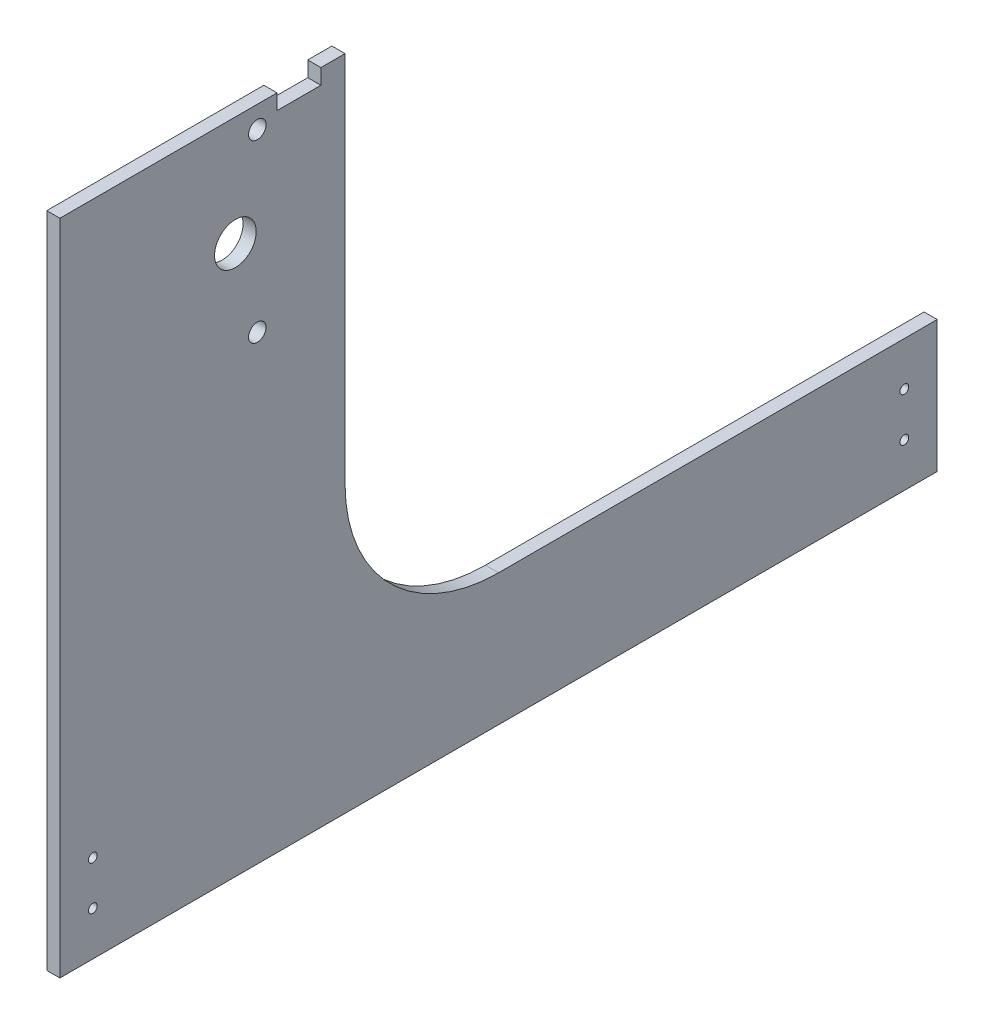
from build123d import *

# Parameters (mm, degrees)
SKETCH1_R           = 4
BOSS_EXTRUDE1_DEPTH = 6
CUT_EXTRUDE1_REACH  = 8
SKETCH3_R           = 9.5
SKETCH4_W           = 50
SKETCH4_H           = 300
BOSS_EXTRUDE2_DEPTH = 6
CUT_EXTRUDE2_REACH  = 8
SKETCH5_R           = 2


with BuildPart() as part:
    # Sketch1 → Boss-Extrude1 (new body)
    with BuildSketch(Plane(origin=(0, 0, 0), x_dir=(0, 0, -1), z_dir=(1, 0, 0))):
        with BuildLine():
            Line((-80, -190), (-80, -250))
            Line((-80, -250), (320, -250))
            Line((320, -250), (320, -190))
            Line((320, -190), (120, -190))
            ThreePointArc((120, -190), (70.502525317, -169.497474683), (50, -120))
            Line((50, -120), (50, 50))
            Line((50, 50), (39, 50))
            Line((39, 50), (39, 43))
            Line((39, 43), (19, 43))
            Line((19, 43), (19, 50))
            Line((19, 50), (-30, 50))
            Line((-30, 50), (-30, -120.049643139))
            ThreePointArc((-30, -120.049643139), (-43.785205981, -163.041073753), (-80, -190))
        make_face()
        with Locations((10, -40)):
            Circle(SKETCH1_R, mode=Mode.SUBTRACT)
        Circle(SKETCH1_R, mode=Mode.SUBTRACT)
        with Locations((10, 40)):
            Circle(SKETCH1_R, mode=Mode.SUBTRACT)
    extrude(amount=BOSS_EXTRUDE1_DEPTH)

    # Sketch3 → Cut-Extrude1 (cut, up to next)
    with BuildSketch(Plane(origin=(6, 0, 0), x_dir=(0, 0, -1), z_dir=(1, 0, 0)), mode=Mode.PRIVATE) as cut_extrude1_sk1:
        Circle(SKETCH3_R)
    cut_extrude1_tool1 = extrude(cut_extrude1_sk1.sketch, amount=-CUT_EXTRUDE1_REACH, mode=Mode.PRIVATE) & part.part
    add(cut_extrude1_tool1.solids().sort_by_distance((6, 0, 0))[0], mode=Mode.SUBTRACT)

    # Sketch4 → Boss-Extrude2 (add)
    with BuildSketch(Plane.ZY):
        with Locations((55, -100)):
            Rectangle(SKETCH4_W, SKETCH4_H)
    extrude(amount=-BOSS_EXTRUDE2_DEPTH)

    # Sketch5 → Cut-Extrude2 (cut, up to next)
    with BuildSketch(Plane.ZY, mode=Mode.PRIVATE) as cut_extrude2_sk1:
        with Locations((65, -210)):
            Circle(SKETCH5_R)
    cut_extrude2_tool1 = extrude(cut_extrude2_sk1.sketch, amount=-CUT_EXTRUDE2_REACH, mode=Mode.PRIVATE) & part.part
    add(cut_extrude2_tool1.solids().sort_by_distance((0, -210, 65))[0], mode=Mode.SUBTRACT)
    # Sketch5 → Cut-Extrude2 (cut, up to next)
    with BuildSketch(Plane.ZY, mode=Mode.PRIVATE) as cut_extrude2_sk2:
        with Locations((65, -230)):
            Circle(SKETCH5_R)
    cut_extrude2_tool2 = extrude(cut_extrude2_sk2.sketch, amount=-CUT_EXTRUDE2_REACH, mode=Mode.PRIVATE) & part.part
    add(cut_extrude2_tool2.solids().sort_by_distance((0, -230, 65))[0], mode=Mode.SUBTRACT)
    # Sketch5 → Cut-Extrude2 (cut, up to next)
    with BuildSketch(Plane.ZY, mode=Mode.PRIVATE) as cut_extrude2_sk3:
        with Locations((-305, -230)):
            Circle(SKETCH5_R)
    cut_extrude2_tool3 = extrude(cut_extrude2_sk3.sketch, amount=-CUT_EXTRUDE2_REACH, mode=Mode.PRIVATE) & part.part
    add(cut_extrude2_tool3.solids().sort_by_distance((0, -230, -305))[0], mode=Mode.SUBTRACT)
    # Sketch5 → Cut-Extrude2 (cut, up to next)
    with BuildSketch(Plane.ZY, mode=Mode.PRIVATE) as cut_extrude2_sk4:
        with Locations((-305, -210)):
            Circle(SKETCH5_R)
    cut_extrude2_tool4 = extrude(cut_extrude2_sk4.sketch, amount=-CUT_EXTRUDE2_REACH, mode=Mode.PRIVATE) & part.part
    add(cut_extrude2_tool4.solids().sort_by_distance((0, -210, -305))[0], mode=Mode.SUBTRACT)


solid = part.part
